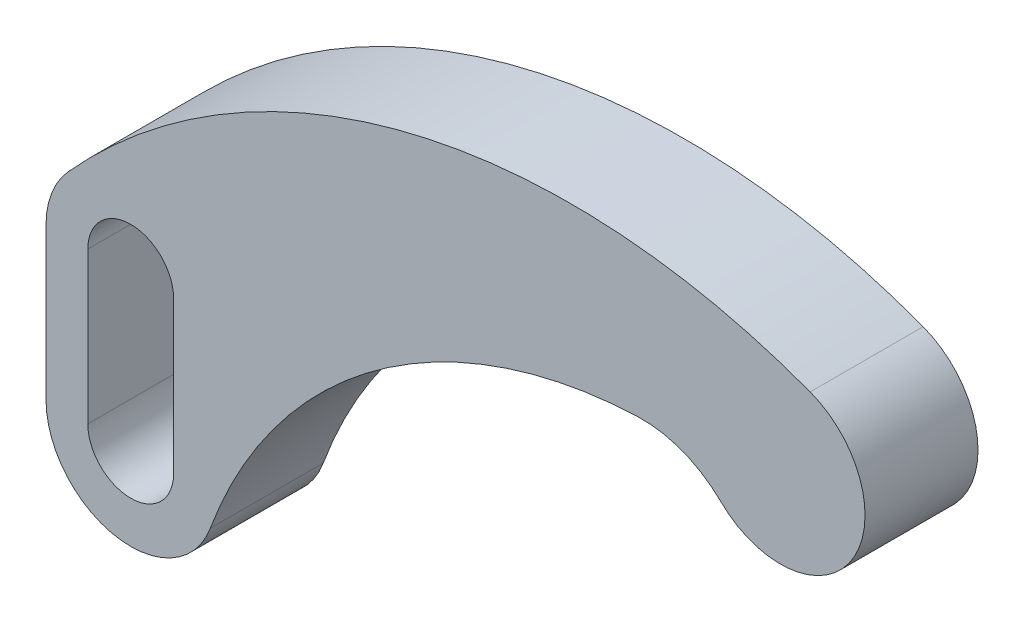
from build123d import *

# Parameters (mm, degrees)
BOSS_EXTRUDE1_DEPTH = 25.4


with BuildPart() as part:
    # Sketch1 → Boss-Extrude1 (new body)
    with BuildSketch(Plane.XY):
        with BuildLine():
            Line((-165.1, -69.596), (-165.1, -35.56))
            ThreePointArc((-165.1, -35.56), (-163.834131861, -28.731592137), (-160.20476074, -22.810676552))
            ThreePointArc((-160.20476074, -22.810676552), (-83.019510627, 23.268882931), (6.709524974, 17.829323448))
            ThreePointArc((6.709524974, 17.829323448), (16.063246399, -10.240830783), (-13.332222743, -13.607142857))
            ThreePointArc((-13.332222743, -13.607142857), (-21.95402191, -8.057064985), (-32.067687872, -6.368116766))
            ThreePointArc((-32.067687872, -6.368116766), (-90.731121166, -26.656656194), (-128.169572983, -76.168125204))
            ThreePointArc((-128.169572983, -76.168125204), (-149.387691218, -88.351327705), (-165.1, -69.596))
        make_face()
        with BuildLine():
            Line((-155.702, -35.56), (-155.702, -69.596))
            ThreePointArc((-155.702, -69.596), (-146.05, -79.248), (-136.398, -69.596))
            Line((-136.398, -69.596), (-136.398, -35.56))
            ThreePointArc((-136.398, -35.56), (-146.05, -25.908), (-155.702, -35.56))
        make_face(mode=Mode.SUBTRACT)
    extrude(amount=BOSS_EXTRUDE1_DEPTH)


solid = part.part
